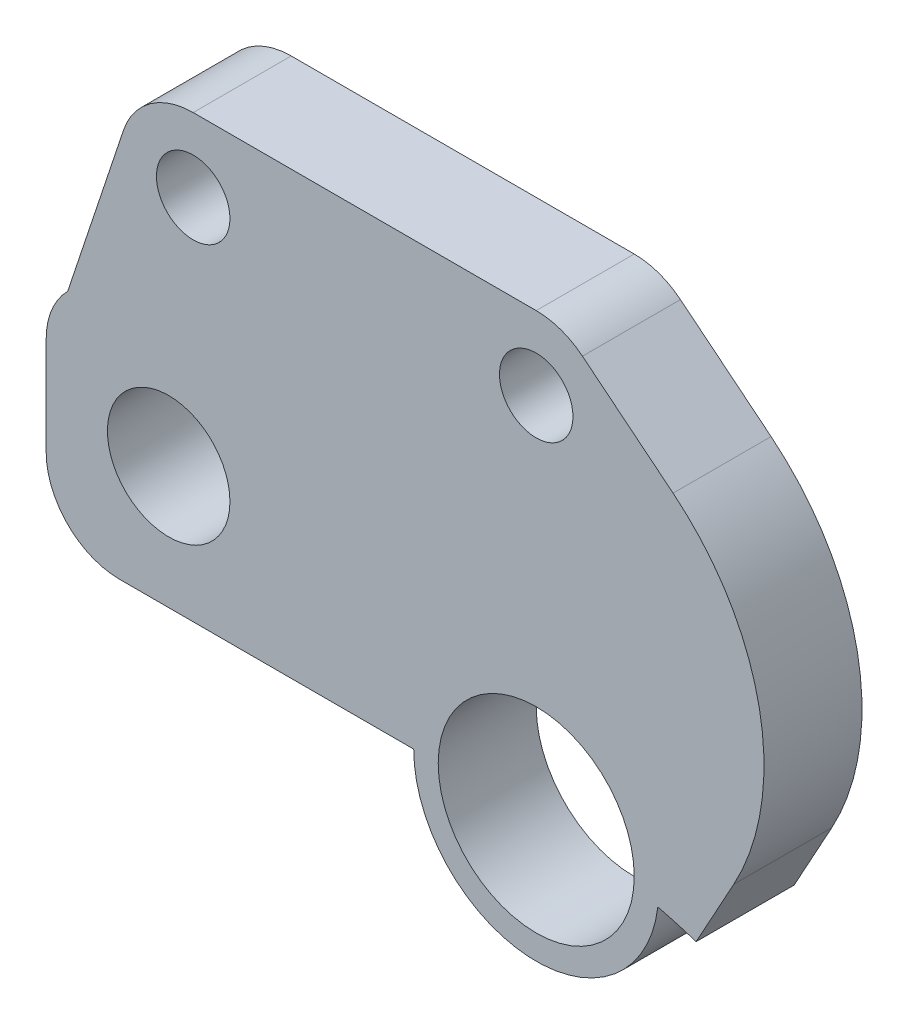
from build123d import *

# Parameters (mm, degrees)
CROQUIS1_R              = 4
CROQUIS1_R_2            = 2.5
CROQUIS1_R_3            = 1.5
SALIENTE_EXTRUIR1_DEPTH = 4
CORTAR_EXTRUIR1_DEPTH   = 10
REDONDEO1_R             = 10


with BuildPart() as part:
    # Croquis1 → Saliente-Extruir1 (new body)
    with BuildSketch(Plane.XY):
        with BuildLine():
            ThreePointArc((13.175908043, 16.287969402), (20.207859701, 17.03070481), (19.465124293, 24.062656467))
            Line((19.465124293, 24.062656467), (1.886764875, 38.28240612))
            ThreePointArc((1.886764875, 38.28240612), (1.000695169, 38.778181249), (0, 38.95))
            Line((0, 38.95), (-14, 38.95))
            ThreePointArc((-14, 38.95), (-15.75421382, 38.383666755), (-16.84611457, 36.898489248))
            Line((-16.84611457, 36.898489248), (-19.121320344, 30.071320344))
            ThreePointArc((-19.121320344, 30.071320344), (-19.771638598, 29.098050297), (-20, 27.95))
            Line((-20, 27.95), (-20, 23.95))
            ThreePointArc((-20, 23.95), (-19.121320344, 21.828679656), (-17, 20.95))
            Line((-17, 20.95), (-5, 20.95))
            ThreePointArc((-5, 20.95), (-0.298863721, 15.958939945), (4.964272191, 20.353341289))
            ThreePointArc((4.964272191, 20.353341289), (9.295071106, 18.775093958), (13.175908043, 16.287969402))
        make_face()
        with Locations((0, 20.95)):
            Circle(CROQUIS1_R, mode=Mode.SUBTRACT)
        with Locations((-15, 25.95)):
            Circle(CROQUIS1_R_2, mode=Mode.SUBTRACT)
        with Locations((0, 35.95)):
            Circle(CROQUIS1_R_3, mode=Mode.SUBTRACT)
        with Locations((-14, 35.95)):
            Circle(CROQUIS1_R_3, mode=Mode.SUBTRACT)
    extrude(amount=SALIENTE_EXTRUIR1_DEPTH)

    # Croquis2 → Cortar-Extruir1 (cut)
    with BuildSketch(Plane.XY.offset(4)):
        with BuildLine():
            Line((12.087138576, 30.030967124), (6.52630373, 19.907532736))
            ThreePointArc((6.52630373, 19.907532736), (10.015967096, 18.400622357), (13.175908043, 16.287969402))
            ThreePointArc((13.175908043, 16.287969402), (20.207859701, 17.03070481), (19.465124293, 24.062656467))
            Line((19.465124293, 24.062656467), (12.087138576, 30.030967124))
        make_face()
    extrude(amount=-CORTAR_EXTRUIR1_DEPTH, mode=Mode.SUBTRACT)

    # Redondeo1
    redondeo1_edges = [part.edges().sort_by_distance(p)[0] for p in [
        (12.087138576, 30.030967124, 2),
    ]]
    fillet(redondeo1_edges, radius=REDONDEO1_R)


solid = part.part
